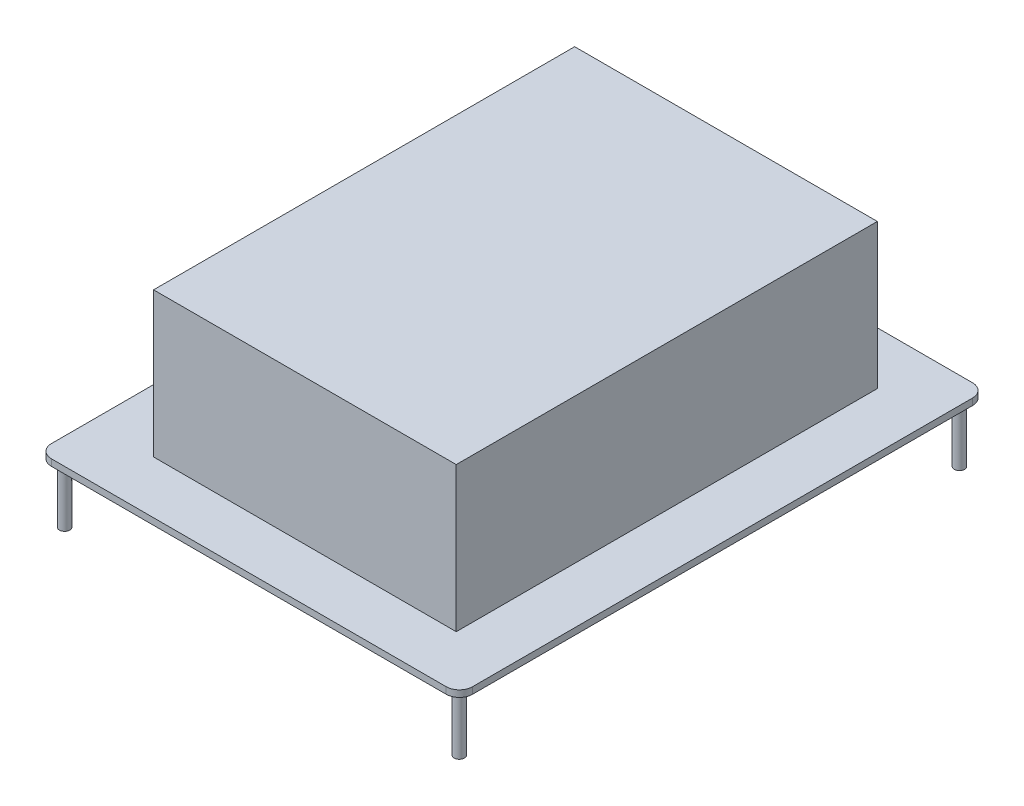
from build123d import *

# Parameters (mm, degrees)
SKETCH1_W           = 81.28
SKETCH1_H           = 101.6
BOSS_EXTRUDE1_DEPTH = 1.27
SKETCH2_W           = 58.42
SKETCH2_H           = 81.28
BOSS_EXTRUDE2_DEPTH = 27.94
FILLET1_R           = 2.54
SKETCH4_R           = 1
BOSS_EXTRUDE3_DEPTH = 11.43


with BuildPart() as part:
    # Sketch1 → Boss-Extrude1 (new body)
    with BuildSketch(Plane(origin=(0, 0, 0), x_dir=(1, 0, 0), z_dir=(0, 1, 0))):
        Rectangle(SKETCH1_W, SKETCH1_H)
    extrude(amount=BOSS_EXTRUDE1_DEPTH)

    # Sketch2 → Boss-Extrude2 (add)
    with BuildSketch(Plane(origin=(0, 1.27, 0), x_dir=(1, 0, 0), z_dir=(0, 1, 0))):
        with Locations((0.667132778, 0)):
            Rectangle(SKETCH2_W, SKETCH2_H)
    extrude(amount=BOSS_EXTRUDE2_DEPTH)

    # Fillet1
    fillet1_edges = [part.edges().sort_by_distance(p)[0] for p in [
        (40.64, 0.635, 50.8),
        (-40.64, 0.635, 50.8),
        (-40.64, 0.635, -50.8),
        (40.64, 0.635, -50.8),
    ]]
    fillet(fillet1_edges, radius=FILLET1_R)

    # Sketch4 → Boss-Extrude3 (add)
    with BuildSketch(Plane.XZ):
        with Locations((38.1, 48.26)):
            Circle(SKETCH4_R)
        with Locations((38.1, -48.26)):
            Circle(SKETCH4_R)
        with Locations((-38.1, 48.26)):
            Circle(SKETCH4_R)
        with Locations((-38.1, -48.26)):
            Circle(SKETCH4_R)
    extrude(amount=BOSS_EXTRUDE3_DEPTH)


solid = part.part
